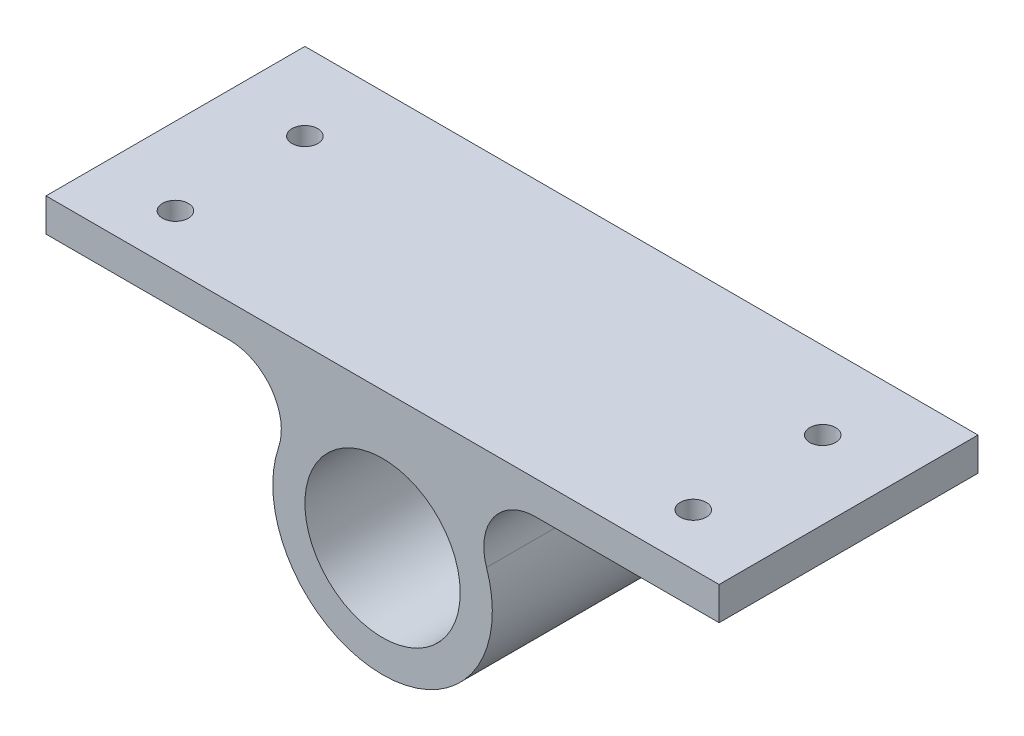
from build123d import *

# Parameters (mm, degrees)
SKETCH1_W           = 650
SKETCH1_H           = 250
SKETCH1_R           = 12.5
BOSS_EXTRUDE1_DEPTH = 119
SKETCH2_R           = 75
CUT_EXTRUDE1_DEPTH  = 267
FILLET1_R           = 50


with BuildPart() as part:
    # Sketch1 → Boss-Extrude1 (new body, symmetric)
    with BuildSketch(Plane(origin=(0, 0, 0), x_dir=(1, 0, 0), z_dir=(0, 1, 0))):
        Rectangle(SKETCH1_W, SKETCH1_H)
        with Locations((-250, -75)):
            Circle(SKETCH1_R, mode=Mode.SUBTRACT)
        with Locations((250, -75)):
            Circle(SKETCH1_R, mode=Mode.SUBTRACT)
        with Locations((250, 50)):
            Circle(SKETCH1_R, mode=Mode.SUBTRACT)
        with Locations((-250, 50)):
            Circle(SKETCH1_R, mode=Mode.SUBTRACT)
    extrude(amount=BOSS_EXTRUDE1_DEPTH, both=True)

    # Sketch2 → Cut-Extrude1 (cut)
    with BuildSketch(Plane.XY.offset(125)):
        with BuildLine():
            Line((-35.156791662, 87), (-325, 87))
            Line((-325, 87), (-325, -119))
            Line((-325, -119), (-5.04e-07, -119))
            ThreePointArc((-5.04e-07, -119), (-104.489233938, -30.832554252), (-35.156791662, 87))
        make_face()
        with BuildLine():
            Line((325, -119), (325, 87))
            Line((325, 87), (35.156791662, 87))
            ThreePointArc((35.156791662, 87), (104.489233853, -30.832554748), (-5.04e-07, -119))
            Line((-5.04e-07, -119), (325, -119))
        make_face()
        with Locations((0, -13)):
            Circle(SKETCH2_R)
    extrude(amount=-CUT_EXTRUDE1_DEPTH, mode=Mode.SUBTRACT)

    # Fillet1
    fillet1_edges = [part.edges().sort_by_distance(p)[0] for p in [
        (-35.156791662, 87, 0),
        (35.156791662, 87, 0),
    ]]
    fillet(fillet1_edges, radius=FILLET1_R)


solid = part.part
